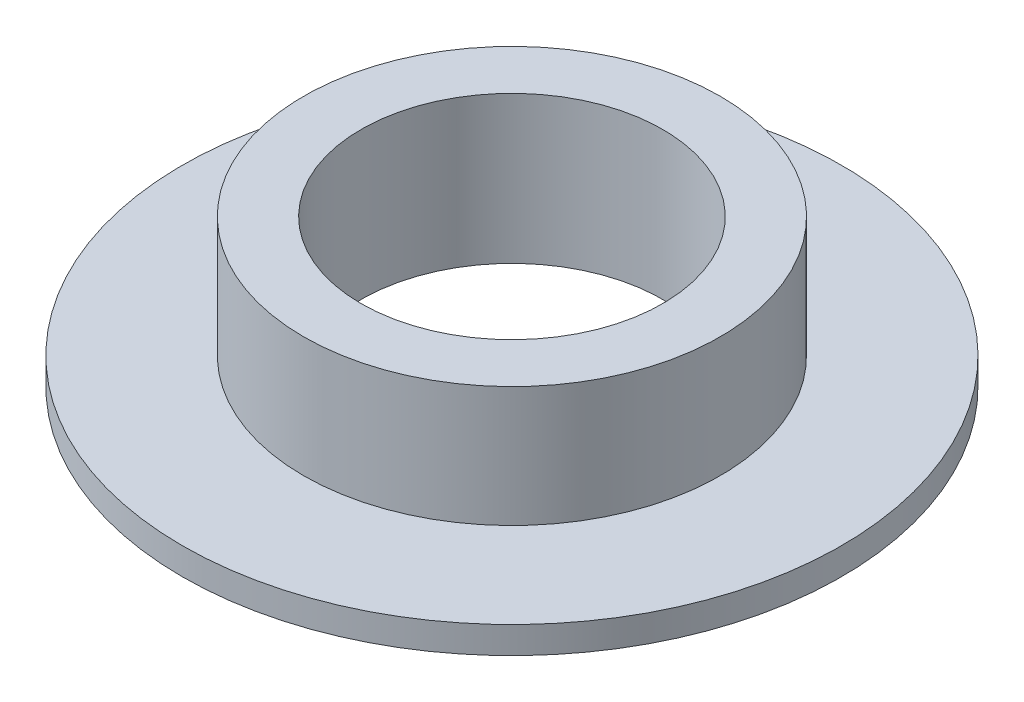
from build123d import *

# Parameters (mm, degrees)
SKETCH1_R           = 23.3045
SKETCH1_R_2         = 14.732
SKETCH1_R_3         = 10.668
BOSS_EXTRUDE1_DEPTH = 1.905
SKETCH1_3_R         = 14.732
SKETCH1_3_R_2       = 10.668
BOSS_EXTRUDE2_DEPTH = 10.414


with BuildPart() as part:
    # Sketch1 → Boss-Extrude1 (new body)
    with BuildSketch(Plane(origin=(0, 0, 0), x_dir=(1, 0, 0), z_dir=(0, 1, 0))):
        with Locations(Location((0, 0, 0), (0, 0, 270))):  # turned: the seam where the file's is
            Circle(SKETCH1_R)
        Circle(SKETCH1_R_2, mode=Mode.SUBTRACT)
        Circle(SKETCH1_R_2)
        with Locations(Location((0, 0, 0), (0, 0, 270))):  # turned: the seam where the file's is
            Circle(SKETCH1_R_3, mode=Mode.SUBTRACT)
    extrude(amount=BOSS_EXTRUDE1_DEPTH)

    # Sketch1_3 → Boss-Extrude2 (add)
    with BuildSketch(Plane(origin=(0, 0, 0), x_dir=(1, 0, 0), z_dir=(0, 1, 0))):
        with Locations(Location((0, 0, 0), (0, 0, 270))):  # turned: the seam where the file's is
            Circle(SKETCH1_3_R)
        with Locations(Location((0, 0, 0), (0, 0, 270))):  # turned: the seam where the file's is
            Circle(SKETCH1_3_R_2, mode=Mode.SUBTRACT)
    extrude(amount=BOSS_EXTRUDE2_DEPTH)


solid = part.part
